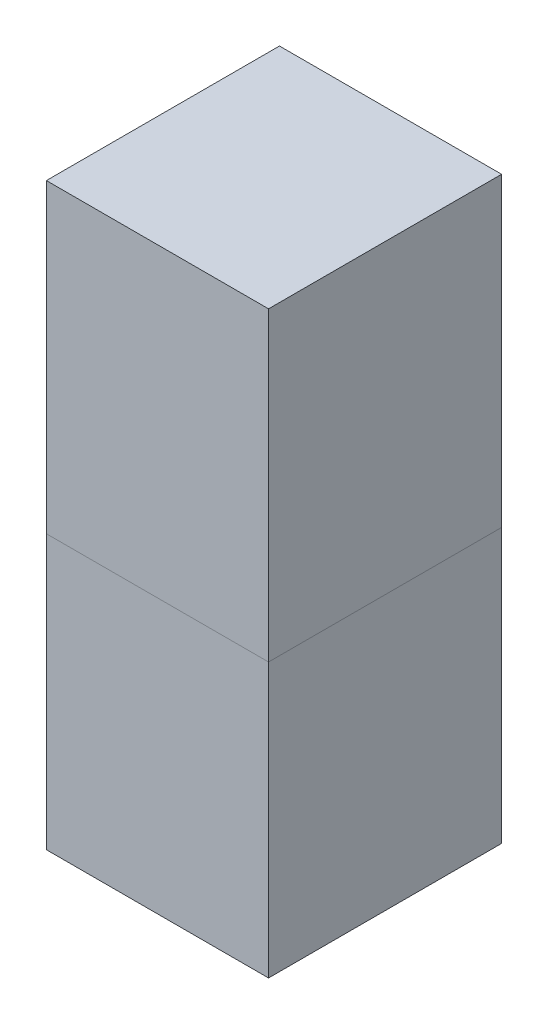
from build123d import *

# Parameters (mm, degrees)
SKETCH3_W           = 690
SKETCH3_H           = 723.9
SKETCH3_W_2         = 688
SKETCH3_H_2         = 721.9
BOSS_EXTRUDE4_DEPTH = 850
SKETCH4_W           = 688
SKETCH4_H           = 721.9
BOSS_EXTRUDE5_DEPTH = 1
SKETCH8_W           = 690
SKETCH8_H           = 723.9
SKETCH8_W_2         = 688
SKETCH8_H_2         = 721.9
BOSS_EXTRUDE7_DEPTH = 0.99
SKETCH10_W          = 688
SKETCH10_H          = 721.9
SKETCH10_W_2        = 687.8
SKETCH10_H_2        = 721.7
BOSS_EXTRUDE8_DEPTH = 1.5
SKETCH16_W          = 690
SKETCH16_H          = 723.9
BOSS_EXTRUDE9_DEPTH = 100


with BuildPart() as part:
    # Sketch3 → Boss-Extrude4 (new body)
    with BuildSketch(Plane(origin=(0, -850, 0), x_dir=(1, 0, 0), z_dir=(0, 1, 0))):
        Rectangle(SKETCH3_W, SKETCH3_H)
        Rectangle(SKETCH3_W_2, SKETCH3_H_2, mode=Mode.SUBTRACT)
    extrude(amount=BOSS_EXTRUDE4_DEPTH)

    # Sketch4 → Boss-Extrude5 (add)
    with BuildSketch(Plane(origin=(0, -850, 0), x_dir=(1, 0, 0), z_dir=(0, 1, 0))):
        Rectangle(SKETCH4_W, SKETCH4_H)
    extrude(amount=BOSS_EXTRUDE5_DEPTH)



with BuildPart() as body_2:
    # Sketch8 → Boss-Extrude7 (new body)
    with BuildSketch(Plane(origin=(0, 0, 0), x_dir=(1, 0, 0), z_dir=(0, 1, 0))):
        Rectangle(SKETCH8_W, SKETCH8_H)
        Rectangle(SKETCH8_W_2, SKETCH8_H_2, mode=Mode.SUBTRACT)
        Rectangle(SKETCH8_W_2, SKETCH8_H_2)
    extrude(amount=-BOSS_EXTRUDE7_DEPTH)


with BuildPart() as part_1:
    add(part.part)

    add(body_2.part)  # Boss-Extrude8 merges body 2
    # Sketch10 → Boss-Extrude8 (add)
    with BuildSketch(Plane(origin=(0, 0, 0), x_dir=(1, 0, 0), z_dir=(0, 1, 0))):
        Rectangle(SKETCH10_W, SKETCH10_H)
        Rectangle(SKETCH10_W_2, SKETCH10_H_2, mode=Mode.SUBTRACT)
    extrude(amount=-BOSS_EXTRUDE8_DEPTH)


with BuildPart() as body_2_2:
    # Body-Move/Copy1: copy of part
    add(part_1.part.moved(Location((0, -850, 0))))


with BuildPart() as part_2:
    add(part_1.part)

    # Sketch16 → Boss-Extrude9 (add)
    with BuildSketch(Plane(origin=(0, 0, 0), x_dir=(1, 0, 0), z_dir=(0, 1, 0))):
        Rectangle(SKETCH16_W, SKETCH16_H)
    extrude(amount=BOSS_EXTRUDE9_DEPTH)


solid = Compound([body_2_2.part, part_2.part])
